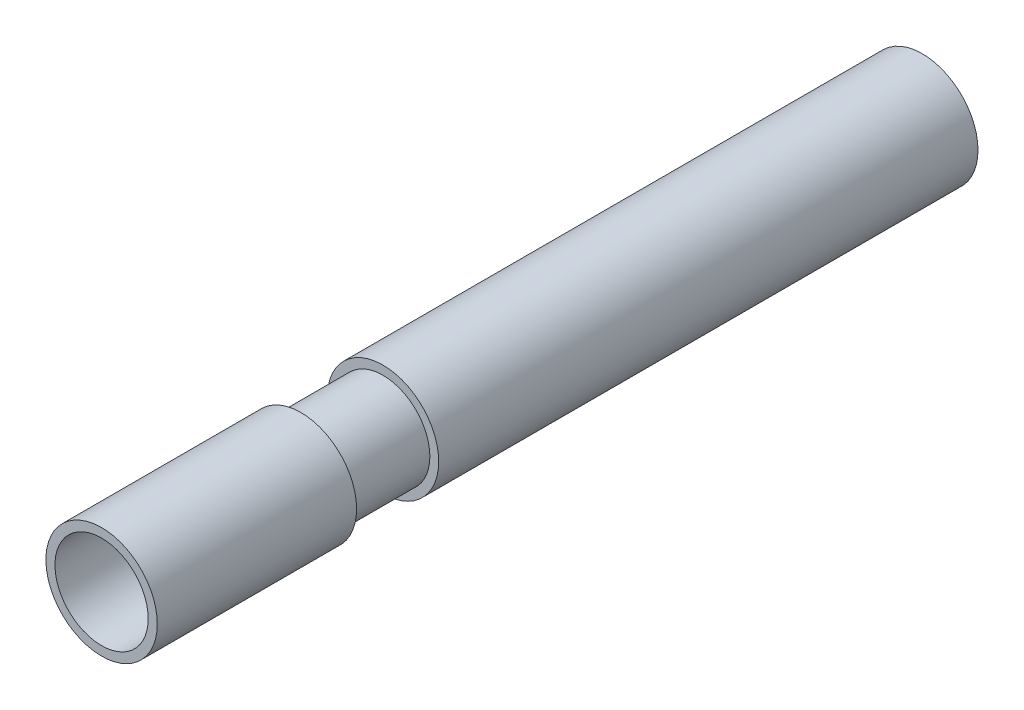
from build123d import *

# Parameters (mm, degrees)
SKETCH2_R          = 2.0193
CUT_EXTRUDE2_DEPTH = 36.56
CUT_SWEEP1_PITCH   = 0.529166667
CUT_SWEEP1_HEIGHT  = 3.704166667
CUT_SWEEP1_RADIUS  = 2.0193


with BuildPart() as part:
    # Sketch1 → Revolve1 (revolve)
    with BuildSketch(Plane(origin=(0, 0, 0), x_dir=(0, 0, -1), z_dir=(1, 0, 0))):
        Polygon((0, 0), (0, 2.413), (8.636, 2.413), (8.636, 2.032), (12.192, 2.032), (12.192, 2.413), (35.56, 2.413), (35.56, 0), align=None)
    revolve(axis=Axis((0, 0, 0), (0, 0, -1)))

    # Sketch2 → Cut-Extrude2 (cut, through all)
    with BuildSketch(Plane.XY):
        Circle(SKETCH2_R)
    extrude(amount=-CUT_EXTRUDE2_DEPTH, mode=Mode.SUBTRACT)

    # Cut-Sweep1: sweep along a helix
    with BuildLine() as cut_sweep1_path:
        Helix(CUT_SWEEP1_PITCH, CUT_SWEEP1_HEIGHT, CUT_SWEEP1_RADIUS, center=(0, 0, -30.48), direction=(0, 0, 1))
    # Sketch12 → Cut-Sweep1 (sweep, cut)
    with BuildSketch(Plane(origin=(0, 0, -30.48), x_dir=(-1, 0, 0), z_dir=(0, 0, -1))):
        Polygon((-1.726006063, 0), (-2.165946968, 0.254), (-2.165946968, -0.254), align=None)
    sweep(path=cut_sweep1_path.line, is_frenet=True, mode=Mode.SUBTRACT)


solid = part.part
